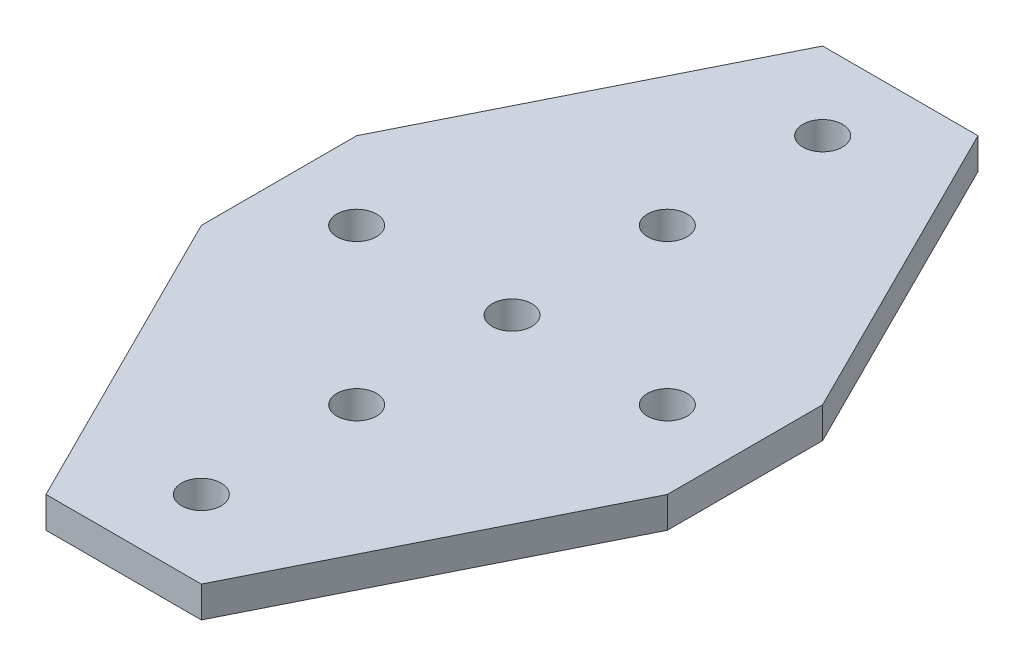
from build123d import *

# Parameters (mm, degrees)
SKETCH1_R           = 2.55
BOSS_EXTRUDE1_DEPTH = 4


with BuildPart() as part:
    # Sketch1 → Boss-Extrude1 (new body)
    with BuildSketch(Plane(origin=(0, 0, 0), x_dir=(1, 0, 0), z_dir=(0, 1, 0))):
        Polygon((30, -10), (10, -50), (-10, -50), (-30, -10), (-30, 10), (-10, 50), (10, 50), (30, 10), align=None)
        with Locations((0, 20)):
            Circle(SKETCH1_R, mode=Mode.SUBTRACT)
        with Locations((0, 40)):
            Circle(SKETCH1_R, mode=Mode.SUBTRACT)
        Circle(SKETCH1_R, mode=Mode.SUBTRACT)
        with Locations((0, -20)):
            Circle(SKETCH1_R, mode=Mode.SUBTRACT)
        with Locations((0, -40)):
            Circle(SKETCH1_R, mode=Mode.SUBTRACT)
        with Locations((-20, 0)):
            Circle(SKETCH1_R, mode=Mode.SUBTRACT)
        with Locations((20, 0)):
            Circle(SKETCH1_R, mode=Mode.SUBTRACT)
    extrude(amount=BOSS_EXTRUDE1_DEPTH)


solid = part.part
